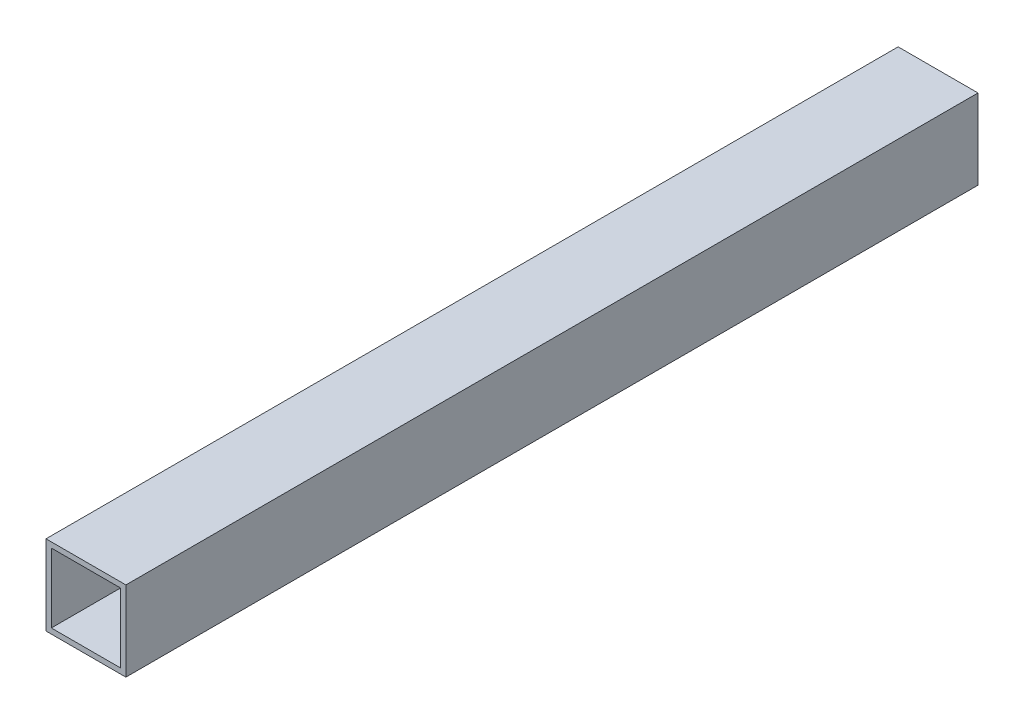
from build123d import *

# Parameters (mm, degrees)
SKETCH3_W           = 15
SKETCH3_H           = 15
SKETCH3_W_2         = 13
SKETCH3_H_2         = 13
EXTRUDE_THIN1_DEPTH = 160


with BuildPart() as part:
    # Sketch3 → Extrude-Thin1 (new body)
    with BuildSketch(Plane.XY):
        with Locations((7.5, 7.5)):
            Rectangle(SKETCH3_W, SKETCH3_H)
        with Locations((7.5, 7.5)):
            Rectangle(SKETCH3_W_2, SKETCH3_H_2, mode=Mode.SUBTRACT)
    extrude(amount=EXTRUDE_THIN1_DEPTH)


solid = part.part
